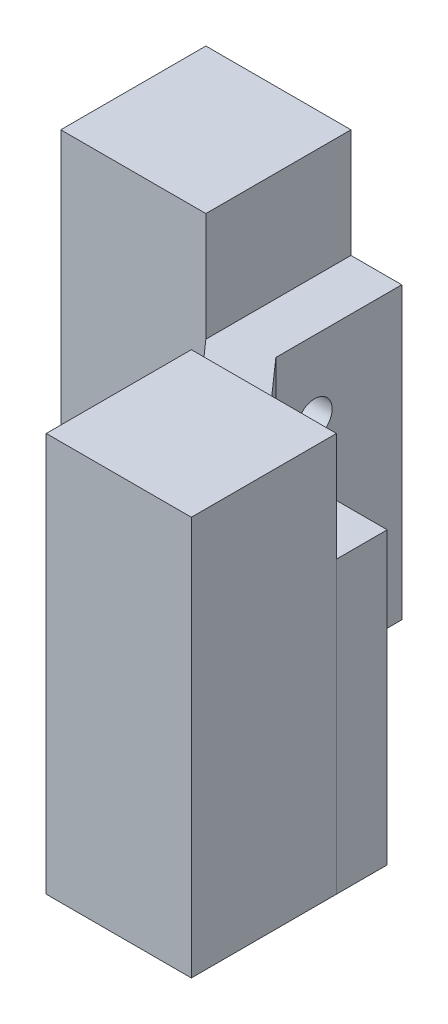
from build123d import *

# Parameters (mm, degrees)
SKETCH1_W                     = 20
SKETCH1_H                     = 20
BOSS_EXTRUDE1_DEPTH           = 55
BOSS_EXTRUDE1_2_DEPTH         = 55
EXTRUDE_THIN1_DEPTH           = 40
SKETCH4_W                     = 2.4
SKETCH4_H                     = 27
M4_CLEARANCE_HOLE1_AT_2_COUNT = 2
M4_CLEARANCE_HOLE1_AT_2_PITCH = 20
MIRROR1_COPY_1_SKETCH_W       = 2.4
MIRROR1_COPY_1_SKETCH_H       = 27


with BuildPart() as part:
    # Sketch1 → Boss-Extrude1 (new body)
    with BuildSketch(Plane(origin=(0, 0, 0), x_dir=(1, 0, 0), z_dir=(0, 1, 0))):
        with Locations((-10, 10)):
            Rectangle(SKETCH1_W, SKETCH1_H)
    extrude(amount=BOSS_EXTRUDE1_DEPTH)


with BuildPart() as body_2:
    # Sketch1 → Boss-Extrude1 2 (new body)
    with BuildSketch(Plane(origin=(0, 0, 0), x_dir=(1, 0, 0), z_dir=(0, 1, 0))):
        with Locations((25.25, -27.25)):
            Rectangle(SKETCH1_W, SKETCH1_H)
    extrude(amount=BOSS_EXTRUDE1_2_DEPTH)


with BuildPart() as body_3:
    # Sketch2 → Extrude-Thin1 (new body)
    with BuildSketch(Plane(origin=(0, 0, 0), x_dir=(1, 0, 0), z_dir=(0, 1, 0))):
        Polygon((0, 20), (0, 0), (15.25, -17.25), (35.25, -17.25), (35.25, -10.25), (18.404846651, -10.25), (7, 2.650564245), (7, 20), align=None)
    extrude(amount=EXTRUDE_THIN1_DEPTH)

    # Sketch4 → M4 Clearance Hole1 (revolve, cut)
    with BuildSketch(Plane(origin=(25.25, 30, 10.25), x_dir=(0, 1, 0), z_dir=(1, 0, 0))):
        with Locations((1.2, 13.5)):
            Rectangle(SKETCH4_W, SKETCH4_H)
    m4_clearance_hole1 = revolve(axis=Axis((25.25, 30, 3.9), (0, 0, 1)), mode=Mode.SUBTRACT)

    # M4 Clearance Hole1 at 2: M4 Clearance Hole1 ×2
    with Locations(*[(0, -i * M4_CLEARANCE_HOLE1_AT_2_PITCH, 0) for i in range(1, M4_CLEARANCE_HOLE1_AT_2_COUNT)]):
        add(m4_clearance_hole1, mode=Mode.SUBTRACT)

    # Mirror1: M4 Clearance Hole1 across plane
    add(m4_clearance_hole1.mirror(Plane(origin=(8.625, 0, 8.625), x_dir=(-0.707106781, 0, 0.707106781), z_dir=(-0.707106781, 0, -0.707106781))), mode=Mode.SUBTRACT)

    # Mirror1 copy 1 sketch → Mirror1 copy 1 (revolve, cut)
    with BuildSketch(Plane(origin=(7, 10, -8), x_dir=(0, 1, 0), z_dir=(0, 0, -1))):
        with Locations((1.2, -13.5)):
            Rectangle(MIRROR1_COPY_1_SKETCH_W, MIRROR1_COPY_1_SKETCH_H)
    revolve(axis=Axis((13.35, 10, -8), (1, 0, 0)), mode=Mode.SUBTRACT)


solid = Compound([part.part, body_2.part, body_3.part])
